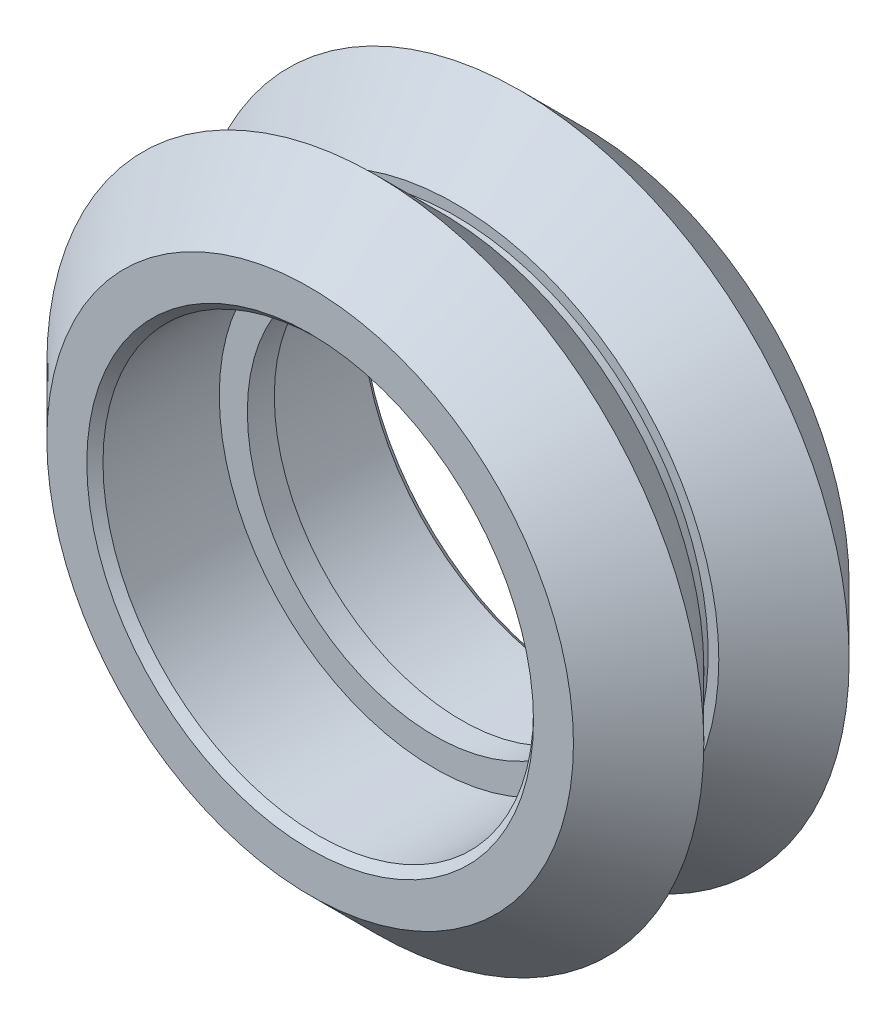
from build123d import *

# Parameters (mm, degrees)
CHAMFER1_SIZE = 0.3


with BuildPart() as part:
    # Sketch1 → Revolve1 (revolve)
    with BuildSketch(Plane(origin=(0, 0, 0), x_dir=(1, 0, 0), z_dir=(0, 1, 0))):
        Polygon((-7.987, 0.5), (-7.987, 5.115), (-9.77, 5.115), (-12.188305192, 2.696694808), (-9.77, 0.278389617), (-9.375, 0.278389617), (-9.375, -0.278389617), (-9.77, -0.278389617), (-12.188305192, -2.696694808), (-9.77, -5.115), (-7.987, -5.115), (-7.987, -0.5), (-6.945, -0.5), (-6.945, 0.5), align=None)
    revolve(axis=Axis((0, 0, -5.115), (0, 0, 1)))

    # Chamfer1
    chamfer1_edges = [part.edges().sort_by_distance(p)[0] for p in [
        (7.987, 0, 5.115),
        (7.987, 0, -5.115),
    ]]
    chamfer(chamfer1_edges, length=CHAMFER1_SIZE)


solid = part.part
